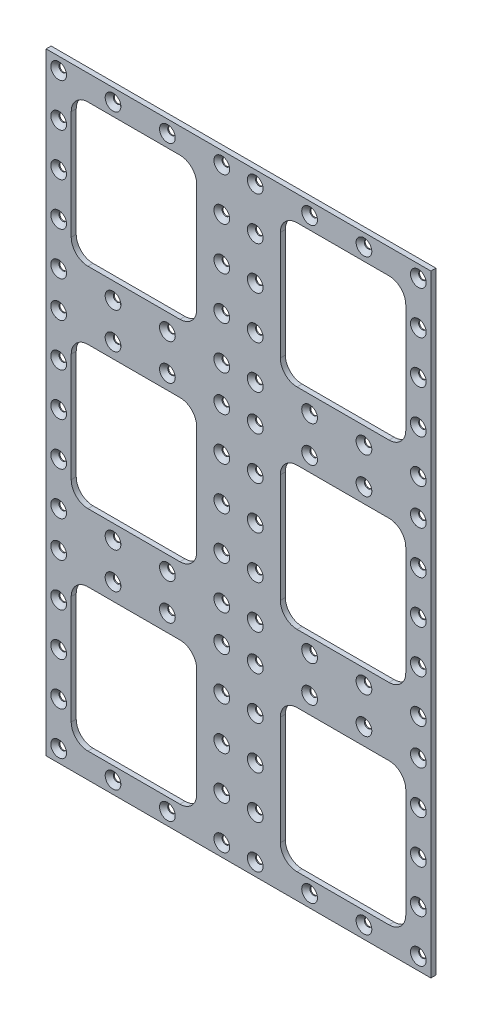
from build123d import *

# Parameters (mm, degrees)
SKETCH1_W              = 230
SKETCH1_H              = 366
BOSS_EXTRUDE1_DEPTH    = 3
SKETCH2_W              = 75
SKETCH2_H              = 85
CUT_EXTRUDE4_DEPTH     = 4
FILLET1_R              = 10
LPATTERN1_COUNT        = 3
LPATTERN1_PITCH        = 125.5
LPATTERN1_COUNT_DIR2   = 2
LPATTERN1_PITCH_DIR2   = 125
FILLET1_OF_LPATTERN1_R = 10
LPATTERN7_COUNT        = 4
LPATTERN7_PITCH        = 32.5
LPATTERN7_COUNT_DIR2   = 5
LPATTERN7_PITCH_DIR2   = 25.65625
LPATTERN8_COUNT        = 3
LPATTERN8_PITCH        = 124.1875


with BuildPart() as part:
    # Sketch1 → Boss-Extrude1 (new body)
    with BuildSketch(Plane.XY):
        Rectangle(SKETCH1_W, SKETCH1_H)
    extrude(amount=BOSS_EXTRUDE1_DEPTH)

    # Sketch2 → Cut-Extrude4 (cut, through all)
    with BuildSketch(Plane.XY):
        with Locations((-62.5, 125.5)):
            Rectangle(SKETCH2_W, SKETCH2_H)
    cut_extrude4 = extrude(amount=CUT_EXTRUDE4_DEPTH, mode=Mode.SUBTRACT)

    # Fillet1
    fillet1_edges = [part.edges().sort_by_distance(p)[0] for p in [
        (-25, 83, 1.5),
        (-25, 168, 1.5),
        (-100, 168, 1.5),
        (-100, 83, 1.5),
    ]]
    fillet(fillet1_edges, radius=FILLET1_R)

    # LPattern1: Cut-Extrude4 3 × 2
    with Locations(*[(j * LPATTERN1_PITCH_DIR2, -i * LPATTERN1_PITCH, 0) for i in range(LPATTERN1_COUNT) for j in range(LPATTERN1_COUNT_DIR2) if (i, j) != (0, 0)]):
        add(cut_extrude4, mode=Mode.SUBTRACT)

    # Fillet1 of LPattern1
    fillet1_of_lpattern1_edges = [part.edges().sort_by_distance(p)[0] for p in [
        (100, 83, 1.5),
        (100, 168, 1.5),
        (25, 168, 1.5),
        (25, 83, 1.5),
        (-25, -42.5, 1.5),
        (-25, 42.5, 1.5),
        (-100, 42.5, 1.5),
        (-100, -42.5, 1.5),
        (100, -42.5, 1.5),
        (100, 42.5, 1.5),
        (25, 42.5, 1.5),
        (25, -42.5, 1.5),
        (-25, -168, 1.5),
        (-25, -83, 1.5),
        (-100, -83, 1.5),
        (-100, -168, 1.5),
        (100, -168, 1.5),
        (100, -83, 1.5),
        (25, -83, 1.5),
        (25, -168, 1.5),
    ]]
    fillet(fillet1_of_lpattern1_edges, radius=FILLET1_OF_LPATTERN1_R)

    # Sketch13 → CSK for M4 Flat Head Machine Screw4 (revolve, cut)
    with BuildSketch(Plane(origin=(-107.5, 175.5, 3), x_dir=(0, -1, 0), z_dir=(1, 0, 0))):
        Polygon((0, 0), (0, 3), (2.25, 3), (2.25, 2.45), (4.7, 0), align=None)
    csk_for_m4_flat_head_machine_screw4 = revolve(axis=Axis((-107.5, 175.5, 9.35), (0, 0, -1)), mode=Mode.SUBTRACT)

    # LPattern7: CSK for M4 Flat Head Machine Screw4 4 × 5, 6 skipped
    with Locations(*[(i * LPATTERN7_PITCH, -j * LPATTERN7_PITCH_DIR2, 0) for i in range(LPATTERN7_COUNT) for j in range(LPATTERN7_COUNT_DIR2) if (i, j) not in ((0, 0), (1, 1), (1, 2), (1, 3), (2, 1), (2, 2), (2, 3))]):
        add(csk_for_m4_flat_head_machine_screw4, mode=Mode.SUBTRACT)

    # LPattern8: CSK for M4 Flat Head Machine Screw4 ×3
    with Locations(*[(0, -i * LPATTERN8_PITCH, 0) for i in range(1, LPATTERN8_COUNT)]):
        add(csk_for_m4_flat_head_machine_screw4, mode=Mode.SUBTRACT)

    # LPattern8 copy 1 sketch → LPattern8 copy 1 (revolve, cut)
    with BuildSketch(Plane(origin=(-107.5, 25.65625, 3), x_dir=(0, -1, 0), z_dir=(1, 0, 0))):
        Polygon((0, 0), (0, 3), (2.25, 3), (2.25, 2.45), (4.7, 0), align=None)
    revolve(axis=Axis((-107.5, 25.65625, 9.35), (0, 0, -1)), mode=Mode.SUBTRACT)

    # LPattern8 copy 2 sketch → LPattern8 copy 2 (revolve, cut)
    with BuildSketch(Plane(origin=(-107.5, -98.53125, 3), x_dir=(0, -1, 0), z_dir=(1, 0, 0))):
        Polygon((0, 0), (0, 3), (2.25, 3), (2.25, 2.45), (4.7, 0), align=None)
    revolve(axis=Axis((-107.5, -98.53125, 9.35), (0, 0, -1)), mode=Mode.SUBTRACT)

    # LPattern8 copy 3 sketch → LPattern8 copy 3 (revolve, cut)
    with BuildSketch(Plane(origin=(-107.5, 0, 3), x_dir=(0, -1, 0), z_dir=(1, 0, 0))):
        Polygon((0, 0), (0, 3), (2.25, 3), (2.25, 2.45), (4.7, 0), align=None)
    revolve(axis=Axis((-107.5, 0, 9.35), (0, 0, -1)), mode=Mode.SUBTRACT)

    # LPattern8 copy 4 sketch → LPattern8 copy 4 (revolve, cut)
    with BuildSketch(Plane(origin=(-107.5, -124.1875, 3), x_dir=(0, -1, 0), z_dir=(1, 0, 0))):
        Polygon((0, 0), (0, 3), (2.25, 3), (2.25, 2.45), (4.7, 0), align=None)
    revolve(axis=Axis((-107.5, -124.1875, 9.35), (0, 0, -1)), mode=Mode.SUBTRACT)

    # LPattern8 copy 5 sketch → LPattern8 copy 5 (revolve, cut)
    with BuildSketch(Plane(origin=(-107.5, -25.65625, 3), x_dir=(0, -1, 0), z_dir=(1, 0, 0))):
        Polygon((0, 0), (0, 3), (2.25, 3), (2.25, 2.45), (4.7, 0), align=None)
    revolve(axis=Axis((-107.5, -25.65625, 9.35), (0, 0, -1)), mode=Mode.SUBTRACT)

    # LPattern8 copy 6 sketch → LPattern8 copy 6 (revolve, cut)
    with BuildSketch(Plane(origin=(-107.5, -149.84375, 3), x_dir=(0, -1, 0), z_dir=(1, 0, 0))):
        Polygon((0, 0), (0, 3), (2.25, 3), (2.25, 2.45), (4.7, 0), align=None)
    revolve(axis=Axis((-107.5, -149.84375, 9.35), (0, 0, -1)), mode=Mode.SUBTRACT)

    # LPattern8 copy 7 sketch → LPattern8 copy 7 (revolve, cut)
    with BuildSketch(Plane(origin=(-107.5, -51.3125, 3), x_dir=(0, -1, 0), z_dir=(1, 0, 0))):
        Polygon((0, 0), (0, 3), (2.25, 3), (2.25, 2.45), (4.7, 0), align=None)
    revolve(axis=Axis((-107.5, -51.3125, 9.35), (0, 0, -1)), mode=Mode.SUBTRACT)

    # LPattern8 copy 8 sketch → LPattern8 copy 8 (revolve, cut)
    with BuildSketch(Plane(origin=(-107.5, -175.5, 3), x_dir=(0, -1, 0), z_dir=(1, 0, 0))):
        Polygon((0, 0), (0, 3), (2.25, 3), (2.25, 2.45), (4.7, 0), align=None)
    revolve(axis=Axis((-107.5, -175.5, 9.35), (0, 0, -1)), mode=Mode.SUBTRACT)

    # LPattern8 copy 9 sketch → LPattern8 copy 9 (revolve, cut)
    with BuildSketch(Plane(origin=(-75, 51.3125, 3), x_dir=(0, -1, 0), z_dir=(1, 0, 0))):
        Polygon((0, 0), (0, 3), (2.25, 3), (2.25, 2.45), (4.7, 0), align=None)
    revolve(axis=Axis((-75, 51.3125, 9.35), (0, 0, -1)), mode=Mode.SUBTRACT)

    # LPattern8 copy 10 sketch → LPattern8 copy 10 (revolve, cut)
    with BuildSketch(Plane(origin=(-75, -72.875, 3), x_dir=(0, -1, 0), z_dir=(1, 0, 0))):
        Polygon((0, 0), (0, 3), (2.25, 3), (2.25, 2.45), (4.7, 0), align=None)
    revolve(axis=Axis((-75, -72.875, 9.35), (0, 0, -1)), mode=Mode.SUBTRACT)

    # LPattern8 copy 11 sketch → LPattern8 copy 11 (revolve, cut)
    with BuildSketch(Plane(origin=(-75, -51.3125, 3), x_dir=(0, -1, 0), z_dir=(1, 0, 0))):
        Polygon((0, 0), (0, 3), (2.25, 3), (2.25, 2.45), (4.7, 0), align=None)
    revolve(axis=Axis((-75, -51.3125, 9.35), (0, 0, -1)), mode=Mode.SUBTRACT)

    # LPattern8 copy 12 sketch → LPattern8 copy 12 (revolve, cut)
    with BuildSketch(Plane(origin=(-75, -175.5, 3), x_dir=(0, -1, 0), z_dir=(1, 0, 0))):
        Polygon((0, 0), (0, 3), (2.25, 3), (2.25, 2.45), (4.7, 0), align=None)
    revolve(axis=Axis((-75, -175.5, 9.35), (0, 0, -1)), mode=Mode.SUBTRACT)

    # LPattern8 copy 13 sketch → LPattern8 copy 13 (revolve, cut)
    with BuildSketch(Plane(origin=(-42.5, 51.3125, 3), x_dir=(0, -1, 0), z_dir=(1, 0, 0))):
        Polygon((0, 0), (0, 3), (2.25, 3), (2.25, 2.45), (4.7, 0), align=None)
    revolve(axis=Axis((-42.5, 51.3125, 9.35), (0, 0, -1)), mode=Mode.SUBTRACT)

    # LPattern8 copy 14 sketch → LPattern8 copy 14 (revolve, cut)
    with BuildSketch(Plane(origin=(-42.5, -72.875, 3), x_dir=(0, -1, 0), z_dir=(1, 0, 0))):
        Polygon((0, 0), (0, 3), (2.25, 3), (2.25, 2.45), (4.7, 0), align=None)
    revolve(axis=Axis((-42.5, -72.875, 9.35), (0, 0, -1)), mode=Mode.SUBTRACT)

    # LPattern8 copy 15 sketch → LPattern8 copy 15 (revolve, cut)
    with BuildSketch(Plane(origin=(-42.5, -51.3125, 3), x_dir=(0, -1, 0), z_dir=(1, 0, 0))):
        Polygon((0, 0), (0, 3), (2.25, 3), (2.25, 2.45), (4.7, 0), align=None)
    revolve(axis=Axis((-42.5, -51.3125, 9.35), (0, 0, -1)), mode=Mode.SUBTRACT)

    # LPattern8 copy 16 sketch → LPattern8 copy 16 (revolve, cut)
    with BuildSketch(Plane(origin=(-42.5, -175.5, 3), x_dir=(0, -1, 0), z_dir=(1, 0, 0))):
        Polygon((0, 0), (0, 3), (2.25, 3), (2.25, 2.45), (4.7, 0), align=None)
    revolve(axis=Axis((-42.5, -175.5, 9.35), (0, 0, -1)), mode=Mode.SUBTRACT)

    # LPattern8 copy 17 sketch → LPattern8 copy 17 (revolve, cut)
    with BuildSketch(Plane(origin=(-10, 51.3125, 3), x_dir=(0, -1, 0), z_dir=(1, 0, 0))):
        Polygon((0, 0), (0, 3), (2.25, 3), (2.25, 2.45), (4.7, 0), align=None)
    revolve(axis=Axis((-10, 51.3125, 9.35), (0, 0, -1)), mode=Mode.SUBTRACT)

    # LPattern8 copy 18 sketch → LPattern8 copy 18 (revolve, cut)
    with BuildSketch(Plane(origin=(-10, -72.875, 3), x_dir=(0, -1, 0), z_dir=(1, 0, 0))):
        Polygon((0, 0), (0, 3), (2.25, 3), (2.25, 2.45), (4.7, 0), align=None)
    revolve(axis=Axis((-10, -72.875, 9.35), (0, 0, -1)), mode=Mode.SUBTRACT)

    # LPattern8 copy 19 sketch → LPattern8 copy 19 (revolve, cut)
    with BuildSketch(Plane(origin=(-10, 25.65625, 3), x_dir=(0, -1, 0), z_dir=(1, 0, 0))):
        Polygon((0, 0), (0, 3), (2.25, 3), (2.25, 2.45), (4.7, 0), align=None)
    revolve(axis=Axis((-10, 25.65625, 9.35), (0, 0, -1)), mode=Mode.SUBTRACT)

    # LPattern8 copy 20 sketch → LPattern8 copy 20 (revolve, cut)
    with BuildSketch(Plane(origin=(-10, -98.53125, 3), x_dir=(0, -1, 0), z_dir=(1, 0, 0))):
        Polygon((0, 0), (0, 3), (2.25, 3), (2.25, 2.45), (4.7, 0), align=None)
    revolve(axis=Axis((-10, -98.53125, 9.35), (0, 0, -1)), mode=Mode.SUBTRACT)

    # LPattern8 copy 21 sketch → LPattern8 copy 21 (revolve, cut)
    with BuildSketch(Plane(origin=(-10, 0, 3), x_dir=(0, -1, 0), z_dir=(1, 0, 0))):
        Polygon((0, 0), (0, 3), (2.25, 3), (2.25, 2.45), (4.7, 0), align=None)
    revolve(axis=Axis((-10, 0, 9.35), (0, 0, -1)), mode=Mode.SUBTRACT)

    # LPattern8 copy 22 sketch → LPattern8 copy 22 (revolve, cut)
    with BuildSketch(Plane(origin=(-10, -124.1875, 3), x_dir=(0, -1, 0), z_dir=(1, 0, 0))):
        Polygon((0, 0), (0, 3), (2.25, 3), (2.25, 2.45), (4.7, 0), align=None)
    revolve(axis=Axis((-10, -124.1875, 9.35), (0, 0, -1)), mode=Mode.SUBTRACT)

    # LPattern8 copy 23 sketch → LPattern8 copy 23 (revolve, cut)
    with BuildSketch(Plane(origin=(-10, -25.65625, 3), x_dir=(0, -1, 0), z_dir=(1, 0, 0))):
        Polygon((0, 0), (0, 3), (2.25, 3), (2.25, 2.45), (4.7, 0), align=None)
    revolve(axis=Axis((-10, -25.65625, 9.35), (0, 0, -1)), mode=Mode.SUBTRACT)

    # LPattern8 copy 24 sketch → LPattern8 copy 24 (revolve, cut)
    with BuildSketch(Plane(origin=(-10, -149.84375, 3), x_dir=(0, -1, 0), z_dir=(1, 0, 0))):
        Polygon((0, 0), (0, 3), (2.25, 3), (2.25, 2.45), (4.7, 0), align=None)
    revolve(axis=Axis((-10, -149.84375, 9.35), (0, 0, -1)), mode=Mode.SUBTRACT)

    # LPattern8 copy 25 sketch → LPattern8 copy 25 (revolve, cut)
    with BuildSketch(Plane(origin=(-10, -51.3125, 3), x_dir=(0, -1, 0), z_dir=(1, 0, 0))):
        Polygon((0, 0), (0, 3), (2.25, 3), (2.25, 2.45), (4.7, 0), align=None)
    revolve(axis=Axis((-10, -51.3125, 9.35), (0, 0, -1)), mode=Mode.SUBTRACT)

    # LPattern8 copy 26 sketch → LPattern8 copy 26 (revolve, cut)
    with BuildSketch(Plane(origin=(-10, -175.5, 3), x_dir=(0, -1, 0), z_dir=(1, 0, 0))):
        Polygon((0, 0), (0, 3), (2.25, 3), (2.25, 2.45), (4.7, 0), align=None)
    revolve(axis=Axis((-10, -175.5, 9.35), (0, 0, -1)), mode=Mode.SUBTRACT)

    # Mirror1: CSK for M4 Flat Head Machine Screw4 across plane
    add(csk_for_m4_flat_head_machine_screw4.mirror(Plane(origin=(0, 0, 0), x_dir=(0, 0, 1), z_dir=(1, 0, 0))), mode=Mode.SUBTRACT)

    # Mirror1 copy 1 sketch → Mirror1 copy 1 (revolve, cut)
    with BuildSketch(Plane(origin=(107.5, 51.3125, 3), x_dir=(0, -1, 0), z_dir=(-1, 0, 0))):
        Polygon((0, 0), (0, -3), (2.25, -3), (2.25, -2.45), (4.7, 0), align=None)
    revolve(axis=Axis((107.5, 51.3125, 9.35), (0, 0, 1)), mode=Mode.SUBTRACT)

    # Mirror1 copy 2 sketch → Mirror1 copy 2 (revolve, cut)
    with BuildSketch(Plane(origin=(107.5, -72.875, 3), x_dir=(0, -1, 0), z_dir=(-1, 0, 0))):
        Polygon((0, 0), (0, -3), (2.25, -3), (2.25, -2.45), (4.7, 0), align=None)
    revolve(axis=Axis((107.5, -72.875, 9.35), (0, 0, 1)), mode=Mode.SUBTRACT)

    # Mirror1 copy 3 sketch → Mirror1 copy 3 (revolve, cut)
    with BuildSketch(Plane(origin=(107.5, 25.65625, 3), x_dir=(0, -1, 0), z_dir=(-1, 0, 0))):
        Polygon((0, 0), (0, -3), (2.25, -3), (2.25, -2.45), (4.7, 0), align=None)
    revolve(axis=Axis((107.5, 25.65625, 9.35), (0, 0, 1)), mode=Mode.SUBTRACT)

    # Mirror1 copy 4 sketch → Mirror1 copy 4 (revolve, cut)
    with BuildSketch(Plane(origin=(107.5, -98.53125, 3), x_dir=(0, -1, 0), z_dir=(-1, 0, 0))):
        Polygon((0, 0), (0, -3), (2.25, -3), (2.25, -2.45), (4.7, 0), align=None)
    revolve(axis=Axis((107.5, -98.53125, 9.35), (0, 0, 1)), mode=Mode.SUBTRACT)

    # Mirror1 copy 5 sketch → Mirror1 copy 5 (revolve, cut)
    with BuildSketch(Plane(origin=(107.5, 0, 3), x_dir=(0, -1, 0), z_dir=(-1, 0, 0))):
        Polygon((0, 0), (0, -3), (2.25, -3), (2.25, -2.45), (4.7, 0), align=None)
    revolve(axis=Axis((107.5, 0, 9.35), (0, 0, 1)), mode=Mode.SUBTRACT)

    # Mirror1 copy 6 sketch → Mirror1 copy 6 (revolve, cut)
    with BuildSketch(Plane(origin=(107.5, -124.1875, 3), x_dir=(0, -1, 0), z_dir=(-1, 0, 0))):
        Polygon((0, 0), (0, -3), (2.25, -3), (2.25, -2.45), (4.7, 0), align=None)
    revolve(axis=Axis((107.5, -124.1875, 9.35), (0, 0, 1)), mode=Mode.SUBTRACT)

    # Mirror1 copy 7 sketch → Mirror1 copy 7 (revolve, cut)
    with BuildSketch(Plane(origin=(107.5, -25.65625, 3), x_dir=(0, -1, 0), z_dir=(-1, 0, 0))):
        Polygon((0, 0), (0, -3), (2.25, -3), (2.25, -2.45), (4.7, 0), align=None)
    revolve(axis=Axis((107.5, -25.65625, 9.35), (0, 0, 1)), mode=Mode.SUBTRACT)

    # Mirror1 copy 8 sketch → Mirror1 copy 8 (revolve, cut)
    with BuildSketch(Plane(origin=(107.5, -149.84375, 3), x_dir=(0, -1, 0), z_dir=(-1, 0, 0))):
        Polygon((0, 0), (0, -3), (2.25, -3), (2.25, -2.45), (4.7, 0), align=None)
    revolve(axis=Axis((107.5, -149.84375, 9.35), (0, 0, 1)), mode=Mode.SUBTRACT)

    # Mirror1 copy 9 sketch → Mirror1 copy 9 (revolve, cut)
    with BuildSketch(Plane(origin=(107.5, -51.3125, 3), x_dir=(0, -1, 0), z_dir=(-1, 0, 0))):
        Polygon((0, 0), (0, -3), (2.25, -3), (2.25, -2.45), (4.7, 0), align=None)
    revolve(axis=Axis((107.5, -51.3125, 9.35), (0, 0, 1)), mode=Mode.SUBTRACT)

    # Mirror1 copy 10 sketch → Mirror1 copy 10 (revolve, cut)
    with BuildSketch(Plane(origin=(107.5, -175.5, 3), x_dir=(0, -1, 0), z_dir=(-1, 0, 0))):
        Polygon((0, 0), (0, -3), (2.25, -3), (2.25, -2.45), (4.7, 0), align=None)
    revolve(axis=Axis((107.5, -175.5, 9.35), (0, 0, 1)), mode=Mode.SUBTRACT)

    # Mirror1 copy 11 sketch → Mirror1 copy 11 (revolve, cut)
    with BuildSketch(Plane(origin=(75, 51.3125, 3), x_dir=(0, -1, 0), z_dir=(-1, 0, 0))):
        Polygon((0, 0), (0, -3), (2.25, -3), (2.25, -2.45), (4.7, 0), align=None)
    revolve(axis=Axis((75, 51.3125, 9.35), (0, 0, 1)), mode=Mode.SUBTRACT)

    # Mirror1 copy 12 sketch → Mirror1 copy 12 (revolve, cut)
    with BuildSketch(Plane(origin=(75, -72.875, 3), x_dir=(0, -1, 0), z_dir=(-1, 0, 0))):
        Polygon((0, 0), (0, -3), (2.25, -3), (2.25, -2.45), (4.7, 0), align=None)
    revolve(axis=Axis((75, -72.875, 9.35), (0, 0, 1)), mode=Mode.SUBTRACT)

    # Mirror1 copy 13 sketch → Mirror1 copy 13 (revolve, cut)
    with BuildSketch(Plane(origin=(75, -51.3125, 3), x_dir=(0, -1, 0), z_dir=(-1, 0, 0))):
        Polygon((0, 0), (0, -3), (2.25, -3), (2.25, -2.45), (4.7, 0), align=None)
    revolve(axis=Axis((75, -51.3125, 9.35), (0, 0, 1)), mode=Mode.SUBTRACT)

    # Mirror1 copy 14 sketch → Mirror1 copy 14 (revolve, cut)
    with BuildSketch(Plane(origin=(75, -175.5, 3), x_dir=(0, -1, 0), z_dir=(-1, 0, 0))):
        Polygon((0, 0), (0, -3), (2.25, -3), (2.25, -2.45), (4.7, 0), align=None)
    revolve(axis=Axis((75, -175.5, 9.35), (0, 0, 1)), mode=Mode.SUBTRACT)

    # Mirror1 copy 15 sketch → Mirror1 copy 15 (revolve, cut)
    with BuildSketch(Plane(origin=(42.5, 51.3125, 3), x_dir=(0, -1, 0), z_dir=(-1, 0, 0))):
        Polygon((0, 0), (0, -3), (2.25, -3), (2.25, -2.45), (4.7, 0), align=None)
    revolve(axis=Axis((42.5, 51.3125, 9.35), (0, 0, 1)), mode=Mode.SUBTRACT)

    # Mirror1 copy 16 sketch → Mirror1 copy 16 (revolve, cut)
    with BuildSketch(Plane(origin=(42.5, -72.875, 3), x_dir=(0, -1, 0), z_dir=(-1, 0, 0))):
        Polygon((0, 0), (0, -3), (2.25, -3), (2.25, -2.45), (4.7, 0), align=None)
    revolve(axis=Axis((42.5, -72.875, 9.35), (0, 0, 1)), mode=Mode.SUBTRACT)

    # Mirror1 copy 17 sketch → Mirror1 copy 17 (revolve, cut)
    with BuildSketch(Plane(origin=(42.5, -51.3125, 3), x_dir=(0, -1, 0), z_dir=(-1, 0, 0))):
        Polygon((0, 0), (0, -3), (2.25, -3), (2.25, -2.45), (4.7, 0), align=None)
    revolve(axis=Axis((42.5, -51.3125, 9.35), (0, 0, 1)), mode=Mode.SUBTRACT)

    # Mirror1 copy 18 sketch → Mirror1 copy 18 (revolve, cut)
    with BuildSketch(Plane(origin=(42.5, -175.5, 3), x_dir=(0, -1, 0), z_dir=(-1, 0, 0))):
        Polygon((0, 0), (0, -3), (2.25, -3), (2.25, -2.45), (4.7, 0), align=None)
    revolve(axis=Axis((42.5, -175.5, 9.35), (0, 0, 1)), mode=Mode.SUBTRACT)

    # Mirror1 copy 19 sketch → Mirror1 copy 19 (revolve, cut)
    with BuildSketch(Plane(origin=(10, 51.3125, 3), x_dir=(0, -1, 0), z_dir=(-1, 0, 0))):
        Polygon((0, 0), (0, -3), (2.25, -3), (2.25, -2.45), (4.7, 0), align=None)
    revolve(axis=Axis((10, 51.3125, 9.35), (0, 0, 1)), mode=Mode.SUBTRACT)

    # Mirror1 copy 20 sketch → Mirror1 copy 20 (revolve, cut)
    with BuildSketch(Plane(origin=(10, -72.875, 3), x_dir=(0, -1, 0), z_dir=(-1, 0, 0))):
        Polygon((0, 0), (0, -3), (2.25, -3), (2.25, -2.45), (4.7, 0), align=None)
    revolve(axis=Axis((10, -72.875, 9.35), (0, 0, 1)), mode=Mode.SUBTRACT)

    # Mirror1 copy 21 sketch → Mirror1 copy 21 (revolve, cut)
    with BuildSketch(Plane(origin=(10, 25.65625, 3), x_dir=(0, -1, 0), z_dir=(-1, 0, 0))):
        Polygon((0, 0), (0, -3), (2.25, -3), (2.25, -2.45), (4.7, 0), align=None)
    revolve(axis=Axis((10, 25.65625, 9.35), (0, 0, 1)), mode=Mode.SUBTRACT)

    # Mirror1 copy 22 sketch → Mirror1 copy 22 (revolve, cut)
    with BuildSketch(Plane(origin=(10, -98.53125, 3), x_dir=(0, -1, 0), z_dir=(-1, 0, 0))):
        Polygon((0, 0), (0, -3), (2.25, -3), (2.25, -2.45), (4.7, 0), align=None)
    revolve(axis=Axis((10, -98.53125, 9.35), (0, 0, 1)), mode=Mode.SUBTRACT)

    # Mirror1 copy 23 sketch → Mirror1 copy 23 (revolve, cut)
    with BuildSketch(Plane(origin=(10, 0, 3), x_dir=(0, -1, 0), z_dir=(-1, 0, 0))):
        Polygon((0, 0), (0, -3), (2.25, -3), (2.25, -2.45), (4.7, 0), align=None)
    revolve(axis=Axis((10, 0, 9.35), (0, 0, 1)), mode=Mode.SUBTRACT)

    # Mirror1 copy 24 sketch → Mirror1 copy 24 (revolve, cut)
    with BuildSketch(Plane(origin=(10, -124.1875, 3), x_dir=(0, -1, 0), z_dir=(-1, 0, 0))):
        Polygon((0, 0), (0, -3), (2.25, -3), (2.25, -2.45), (4.7, 0), align=None)
    revolve(axis=Axis((10, -124.1875, 9.35), (0, 0, 1)), mode=Mode.SUBTRACT)

    # Mirror1 copy 25 sketch → Mirror1 copy 25 (revolve, cut)
    with BuildSketch(Plane(origin=(10, -25.65625, 3), x_dir=(0, -1, 0), z_dir=(-1, 0, 0))):
        Polygon((0, 0), (0, -3), (2.25, -3), (2.25, -2.45), (4.7, 0), align=None)
    revolve(axis=Axis((10, -25.65625, 9.35), (0, 0, 1)), mode=Mode.SUBTRACT)

    # Mirror1 copy 26 sketch → Mirror1 copy 26 (revolve, cut)
    with BuildSketch(Plane(origin=(10, -149.84375, 3), x_dir=(0, -1, 0), z_dir=(-1, 0, 0))):
        Polygon((0, 0), (0, -3), (2.25, -3), (2.25, -2.45), (4.7, 0), align=None)
    revolve(axis=Axis((10, -149.84375, 9.35), (0, 0, 1)), mode=Mode.SUBTRACT)

    # Mirror1 copy 27 sketch → Mirror1 copy 27 (revolve, cut)
    with BuildSketch(Plane(origin=(10, -51.3125, 3), x_dir=(0, -1, 0), z_dir=(-1, 0, 0))):
        Polygon((0, 0), (0, -3), (2.25, -3), (2.25, -2.45), (4.7, 0), align=None)
    revolve(axis=Axis((10, -51.3125, 9.35), (0, 0, 1)), mode=Mode.SUBTRACT)

    # Mirror1 copy 28 sketch → Mirror1 copy 28 (revolve, cut)
    with BuildSketch(Plane(origin=(10, -175.5, 3), x_dir=(0, -1, 0), z_dir=(-1, 0, 0))):
        Polygon((0, 0), (0, -3), (2.25, -3), (2.25, -2.45), (4.7, 0), align=None)
    revolve(axis=Axis((10, -175.5, 9.35), (0, 0, 1)), mode=Mode.SUBTRACT)

    # Mirror1 copy 29 sketch → Mirror1 copy 29 (revolve, cut)
    with BuildSketch(Plane(origin=(107.5, 149.84375, 3), x_dir=(0, -1, 0), z_dir=(-1, 0, 0))):
        Polygon((0, 0), (0, -3), (2.25, -3), (2.25, -2.45), (4.7, 0), align=None)
    revolve(axis=Axis((107.5, 149.84375, 9.35), (0, 0, 1)), mode=Mode.SUBTRACT)

    # Mirror1 copy 30 sketch → Mirror1 copy 30 (revolve, cut)
    with BuildSketch(Plane(origin=(107.5, 124.1875, 3), x_dir=(0, -1, 0), z_dir=(-1, 0, 0))):
        Polygon((0, 0), (0, -3), (2.25, -3), (2.25, -2.45), (4.7, 0), align=None)
    revolve(axis=Axis((107.5, 124.1875, 9.35), (0, 0, 1)), mode=Mode.SUBTRACT)

    # Mirror1 copy 31 sketch → Mirror1 copy 31 (revolve, cut)
    with BuildSketch(Plane(origin=(107.5, 98.53125, 3), x_dir=(0, -1, 0), z_dir=(-1, 0, 0))):
        Polygon((0, 0), (0, -3), (2.25, -3), (2.25, -2.45), (4.7, 0), align=None)
    revolve(axis=Axis((107.5, 98.53125, 9.35), (0, 0, 1)), mode=Mode.SUBTRACT)

    # Mirror1 copy 32 sketch → Mirror1 copy 32 (revolve, cut)
    with BuildSketch(Plane(origin=(107.5, 72.875, 3), x_dir=(0, -1, 0), z_dir=(-1, 0, 0))):
        Polygon((0, 0), (0, -3), (2.25, -3), (2.25, -2.45), (4.7, 0), align=None)
    revolve(axis=Axis((107.5, 72.875, 9.35), (0, 0, 1)), mode=Mode.SUBTRACT)

    # Mirror1 copy 33 sketch → Mirror1 copy 33 (revolve, cut)
    with BuildSketch(Plane(origin=(75, 175.5, 3), x_dir=(0, -1, 0), z_dir=(-1, 0, 0))):
        Polygon((0, 0), (0, -3), (2.25, -3), (2.25, -2.45), (4.7, 0), align=None)
    revolve(axis=Axis((75, 175.5, 9.35), (0, 0, 1)), mode=Mode.SUBTRACT)

    # Mirror1 copy 34 sketch → Mirror1 copy 34 (revolve, cut)
    with BuildSketch(Plane(origin=(75, 72.875, 3), x_dir=(0, -1, 0), z_dir=(-1, 0, 0))):
        Polygon((0, 0), (0, -3), (2.25, -3), (2.25, -2.45), (4.7, 0), align=None)
    revolve(axis=Axis((75, 72.875, 9.35), (0, 0, 1)), mode=Mode.SUBTRACT)

    # Mirror1 copy 35 sketch → Mirror1 copy 35 (revolve, cut)
    with BuildSketch(Plane(origin=(42.5, 175.5, 3), x_dir=(0, -1, 0), z_dir=(-1, 0, 0))):
        Polygon((0, 0), (0, -3), (2.25, -3), (2.25, -2.45), (4.7, 0), align=None)
    revolve(axis=Axis((42.5, 175.5, 9.35), (0, 0, 1)), mode=Mode.SUBTRACT)

    # Mirror1 copy 36 sketch → Mirror1 copy 36 (revolve, cut)
    with BuildSketch(Plane(origin=(42.5, 72.875, 3), x_dir=(0, -1, 0), z_dir=(-1, 0, 0))):
        Polygon((0, 0), (0, -3), (2.25, -3), (2.25, -2.45), (4.7, 0), align=None)
    revolve(axis=Axis((42.5, 72.875, 9.35), (0, 0, 1)), mode=Mode.SUBTRACT)

    # Mirror1 copy 37 sketch → Mirror1 copy 37 (revolve, cut)
    with BuildSketch(Plane(origin=(10, 175.5, 3), x_dir=(0, -1, 0), z_dir=(-1, 0, 0))):
        Polygon((0, 0), (0, -3), (2.25, -3), (2.25, -2.45), (4.7, 0), align=None)
    revolve(axis=Axis((10, 175.5, 9.35), (0, 0, 1)), mode=Mode.SUBTRACT)

    # Mirror1 copy 38 sketch → Mirror1 copy 38 (revolve, cut)
    with BuildSketch(Plane(origin=(10, 149.84375, 3), x_dir=(0, -1, 0), z_dir=(-1, 0, 0))):
        Polygon((0, 0), (0, -3), (2.25, -3), (2.25, -2.45), (4.7, 0), align=None)
    revolve(axis=Axis((10, 149.84375, 9.35), (0, 0, 1)), mode=Mode.SUBTRACT)

    # Mirror1 copy 39 sketch → Mirror1 copy 39 (revolve, cut)
    with BuildSketch(Plane(origin=(10, 124.1875, 3), x_dir=(0, -1, 0), z_dir=(-1, 0, 0))):
        Polygon((0, 0), (0, -3), (2.25, -3), (2.25, -2.45), (4.7, 0), align=None)
    revolve(axis=Axis((10, 124.1875, 9.35), (0, 0, 1)), mode=Mode.SUBTRACT)

    # Mirror1 copy 40 sketch → Mirror1 copy 40 (revolve, cut)
    with BuildSketch(Plane(origin=(10, 98.53125, 3), x_dir=(0, -1, 0), z_dir=(-1, 0, 0))):
        Polygon((0, 0), (0, -3), (2.25, -3), (2.25, -2.45), (4.7, 0), align=None)
    revolve(axis=Axis((10, 98.53125, 9.35), (0, 0, 1)), mode=Mode.SUBTRACT)

    # Mirror1 copy 41 sketch → Mirror1 copy 41 (revolve, cut)
    with BuildSketch(Plane(origin=(10, 72.875, 3), x_dir=(0, -1, 0), z_dir=(-1, 0, 0))):
        Polygon((0, 0), (0, -3), (2.25, -3), (2.25, -2.45), (4.7, 0), align=None)
    revolve(axis=Axis((10, 72.875, 9.35), (0, 0, 1)), mode=Mode.SUBTRACT)


solid = part.part
